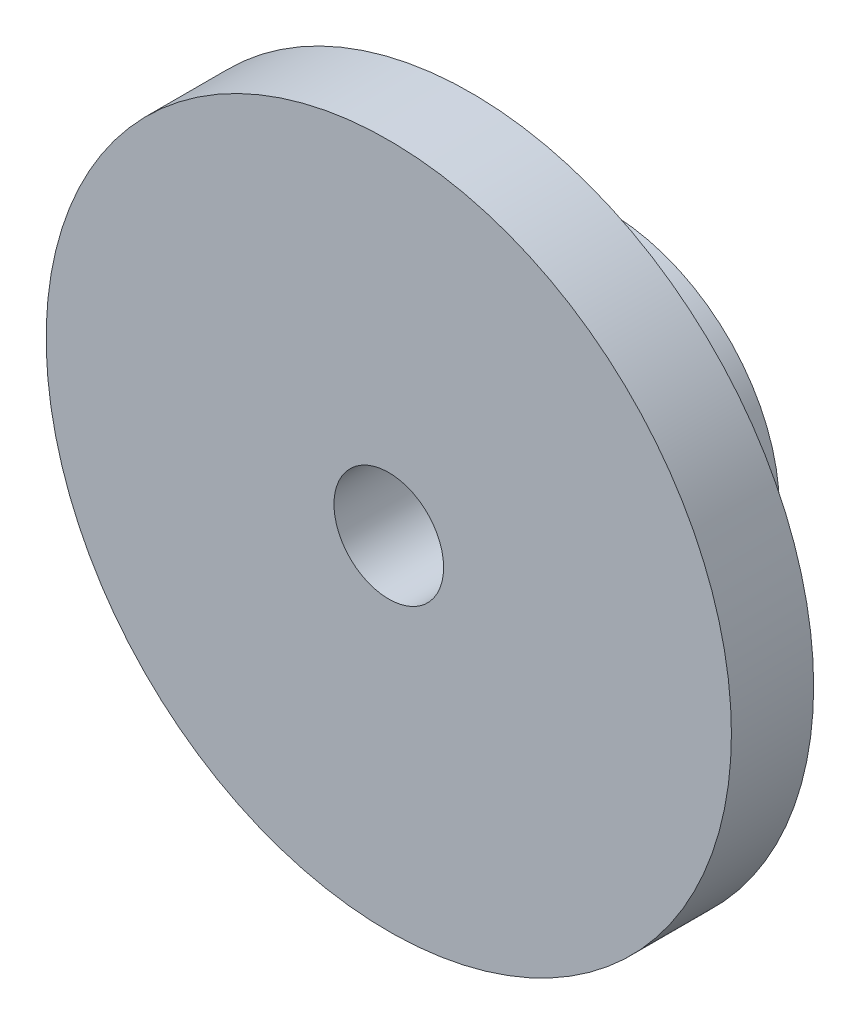
from build123d import *

# Parameters (mm, degrees)
SKETCH_1_R      = 25
SKETCH_1_R_2    = 4
EXTRUDE_1_DEPTH = 6
EXTRUDE_START   = -10
SKETCH_1_3_R    = 12.5
SKETCH_1_3_R_2  = 4
EXTRUDE_2_DEPTH = 10


with BuildPart() as part:
    # Эскиз1 → Бобышка-Вытянуть1 (new body)
    with BuildSketch(Plane.XY):
        Circle(SKETCH_1_R)
        Circle(SKETCH_1_R_2, mode=Mode.SUBTRACT)
    extrude(amount=EXTRUDE_1_DEPTH)

    # Эскиз1<3> → Бобышка-Вытянуть2 (add)
    with BuildSketch(Plane.XY.offset(EXTRUDE_START)):
        Circle(SKETCH_1_3_R)
        Circle(SKETCH_1_3_R_2, mode=Mode.SUBTRACT)
    extrude(amount=EXTRUDE_2_DEPTH)


solid = part.part
